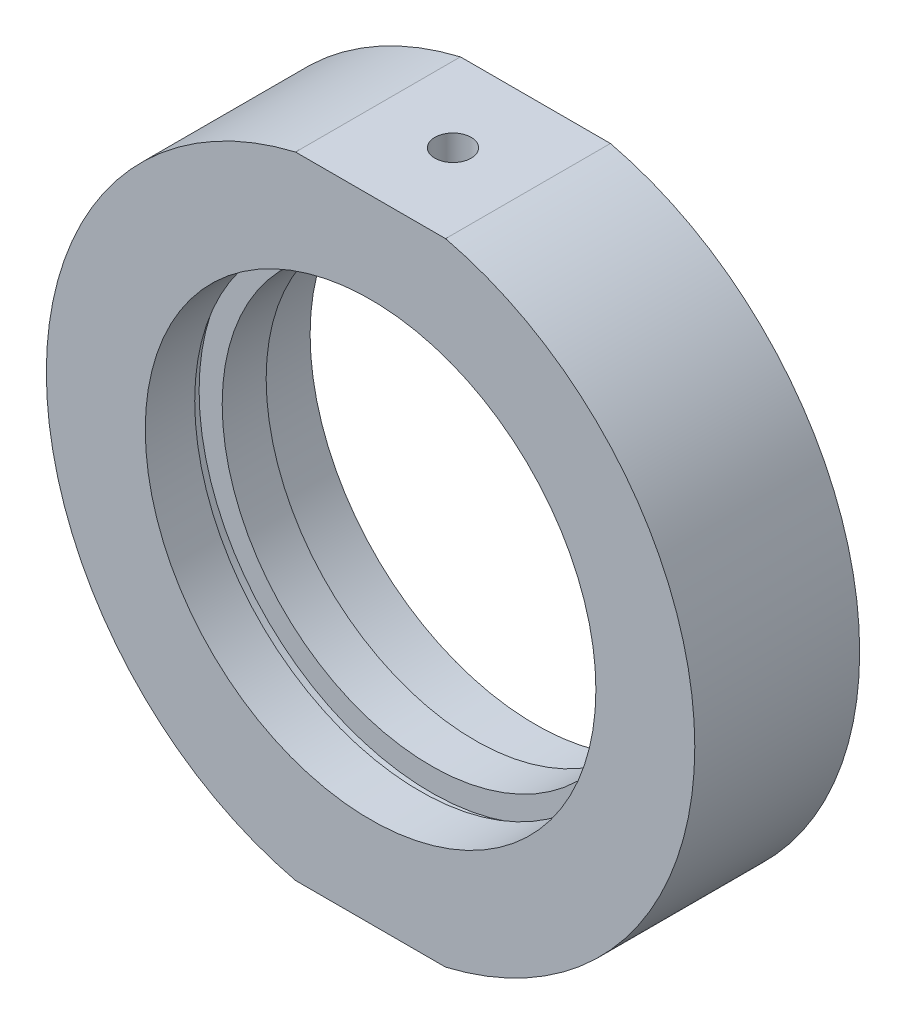
from build123d import *

# Parameters (mm, degrees)
SKETCH_2_W             = 64.02174429
SKETCH_2_H             = 9.248919907
CUT_EXTRUDE_1_DEPTH    = 49
HOLE_WIZARD_M4_2_D     = 3.3
HOLE_WIZARD_M4_2_DEPTH = 5.5
HOLE_WIZARD_M4_2_TIP   = 0.991420021
HOLE_WIZARD_M6_2_D     = 5
HOLE_WIZARD_M6_2_DEPTH = 5.5
HOLE_WIZARD_M6_2_TIP   = 1.502151548


with BuildPart() as part:
    # 草图1 → 旋转1 (revolve)
    with BuildSketch(Plane(origin=(0, 0, 0), x_dir=(1, 0, 0), z_dir=(0, 1, 0)), mode=Mode.PRIVATE) as revolve_1_sk:
        Polygon((29.5, 7.5), (29.5, -7.5), (20.5, -7.5), (20.5, -3), (21.1, -3), (21.1, -2), (19, -2), (19, 2), (21.1, 2), (21.1, 3), (20.5, 3), (20.5, 7.5), align=None)
    revolve(revolve_1_sk.sketch.rotate(Axis((0, 0, -31.9390681), (0, 0, 1)), 180), axis=Axis((0, 0, -31.9390681), (0, 0, 1)))  # turned: the seam where the file's is

    # 草图2 → 切除-拉伸1 (cut)
    with BuildSketch(Plane.XY.offset(7.5)):
        with Locations((-1.141100508, 33.324459954)):
            Rectangle(SKETCH_2_W, SKETCH_2_H)
        with Locations((-1.141100508, -33.324459954)):
            Rectangle(SKETCH_2_W, SKETCH_2_H)
    extrude(amount=-CUT_EXTRUDE_1_DEPTH, mode=Mode.SUBTRACT)

    # M4 螺纹孔2
    with Locations(Plane(origin=(0, 28.7, 0), x_dir=(1, 0, 0), z_dir=(0, 1, 0))):
        with Locations((0, 0)):
            Hole(HOLE_WIZARD_M4_2_D / 2, depth=HOLE_WIZARD_M4_2_DEPTH)
            with Locations((0, 0, -(HOLE_WIZARD_M4_2_DEPTH + HOLE_WIZARD_M4_2_TIP / 2))):  # 118° drill point
                Cone(0, HOLE_WIZARD_M4_2_D / 2, HOLE_WIZARD_M4_2_TIP, mode=Mode.SUBTRACT)

    # M6 螺纹孔2
    with Locations(Plane(origin=(0, -28.7, 0), x_dir=(-1, 0, 0), z_dir=(0, -1, 0))):
        with Locations((0, 0)):
            Hole(HOLE_WIZARD_M6_2_D / 2, depth=HOLE_WIZARD_M6_2_DEPTH)
            with Locations((0, 0, -(HOLE_WIZARD_M6_2_DEPTH + HOLE_WIZARD_M6_2_TIP / 2))):  # 118° drill point
                Cone(0, HOLE_WIZARD_M6_2_D / 2, HOLE_WIZARD_M6_2_TIP, mode=Mode.SUBTRACT)


solid = part.part
